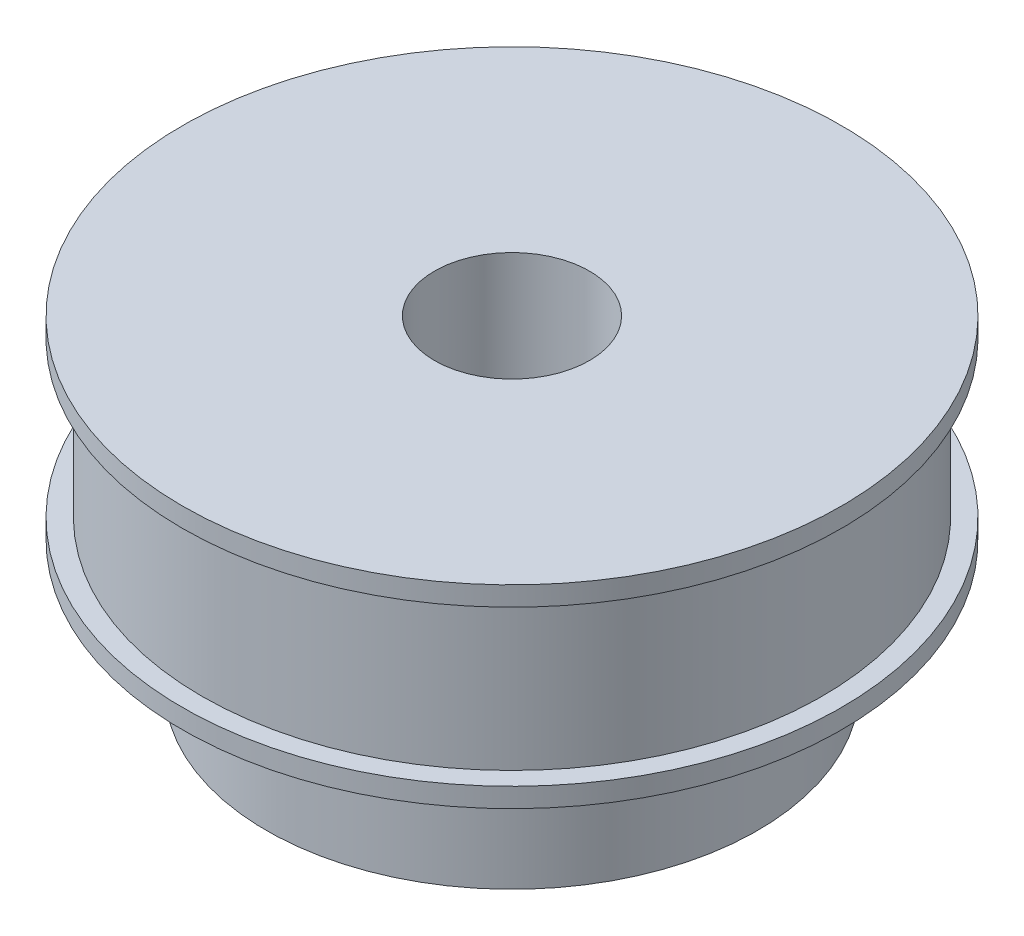
from build123d import *

# Parameters (mm, degrees)
SKETCH1_R           = 24
BOSS_EXTRUDE1_DEPTH = 12
SKETCH3_R           = 25.5
BOSS_EXTRUDE3_DEPTH = 1.5
SKETCH4_R           = 25.5
BOSS_EXTRUDE4_DEPTH = 1.5
SKETCH5_R           = 19
BOSS_EXTRUDE5_DEPTH = 10
SKETCH6_R           = 6
CUT_EXTRUDE1_DEPTH  = 25


with BuildPart() as part:
    # Sketch1 → Boss-Extrude1 (new body)
    with BuildSketch(Plane(origin=(0, 0, 0), x_dir=(1, 0, 0), z_dir=(0, 1, 0))):
        Circle(SKETCH1_R)
    extrude(amount=BOSS_EXTRUDE1_DEPTH)

    # Sketch3 → Boss-Extrude3 (add)
    with BuildSketch(Plane(origin=(0, 12, 0), x_dir=(1, 0, 0), z_dir=(0, 1, 0))):
        Circle(SKETCH3_R)
    extrude(amount=BOSS_EXTRUDE3_DEPTH)

    # Sketch4 → Boss-Extrude4 (add)
    with BuildSketch(Plane.XZ):
        Circle(SKETCH4_R)
    extrude(amount=BOSS_EXTRUDE4_DEPTH)

    # Sketch5 → Boss-Extrude5 (add)
    with BuildSketch(Plane.XZ.offset(1.5)):
        Circle(SKETCH5_R)
    extrude(amount=BOSS_EXTRUDE5_DEPTH)

    # Sketch6 → Cut-Extrude1 (cut)
    with BuildSketch(Plane(origin=(0, 13.5, 0), x_dir=(1, 0, 0), z_dir=(0, 1, 0))):
        Circle(SKETCH6_R)
    extrude(amount=-CUT_EXTRUDE1_DEPTH, mode=Mode.SUBTRACT)


solid = part.part
